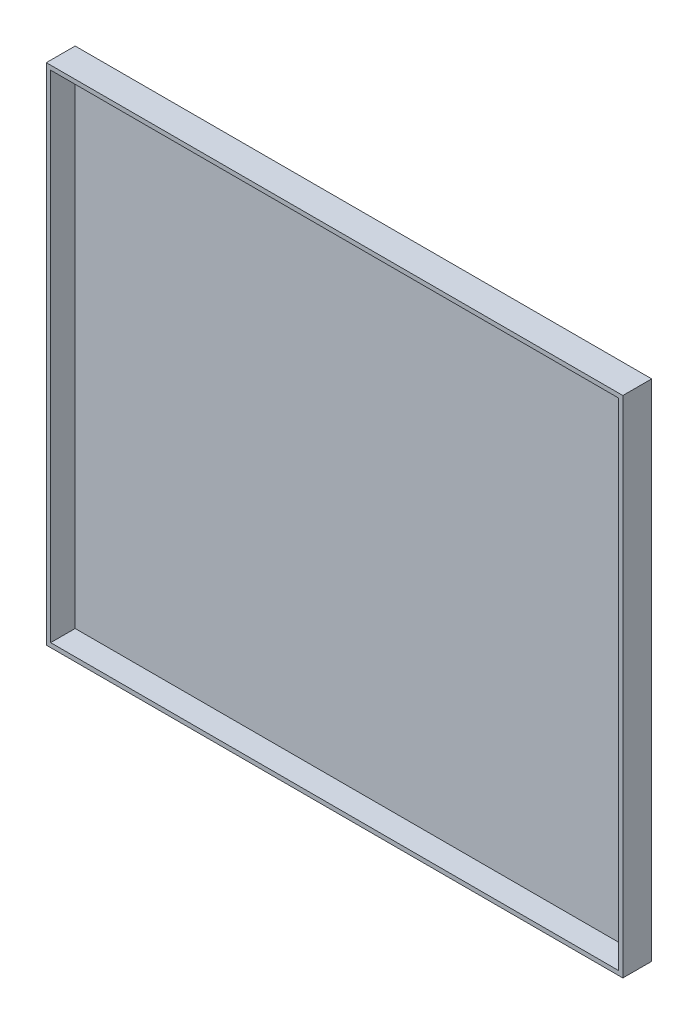
from build123d import *

# Parameters (mm, degrees)
SKETCH_1_W      = 400
SKETCH_1_H      = 350
EXTRUDE_1_DEPTH = 20
SHELL_1_T       = -3


with BuildPart() as part:
    # 草图1 → 凸台-拉伸1 (new body)
    with BuildSketch(Plane.XY):
        Rectangle(SKETCH_1_W, SKETCH_1_H)
    extrude(amount=EXTRUDE_1_DEPTH)

    # 抽壳1
    shell_1_openings = [part.faces().sort_by_distance(p)[0] for p in [
        (0, 0, 20),
    ]]
    offset(amount=SHELL_1_T, openings=shell_1_openings, kind=Kind.INTERSECTION)


solid = part.part
